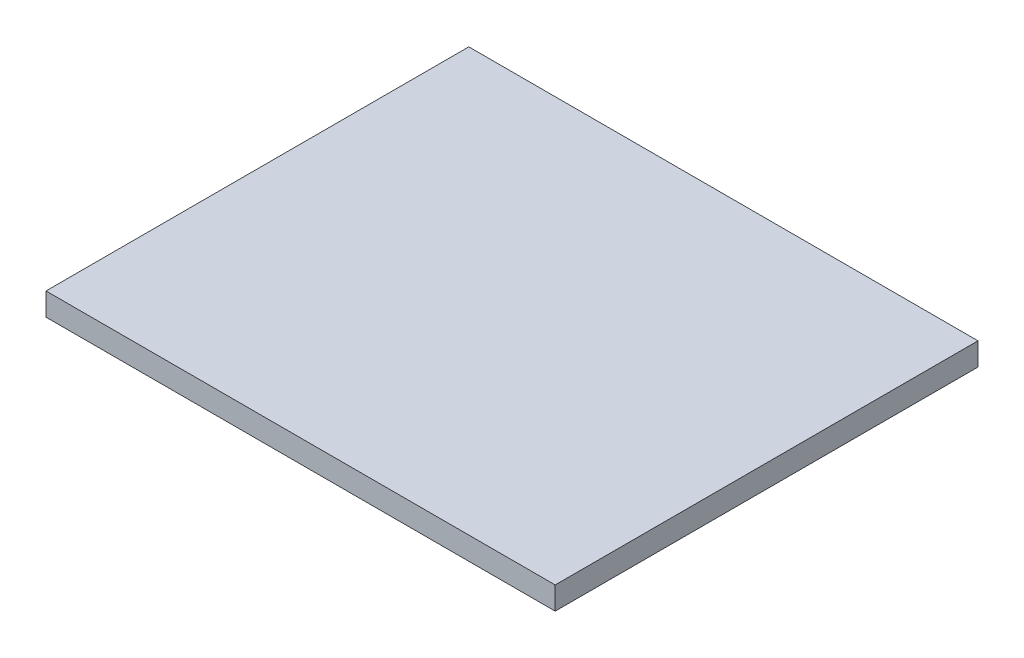
from build123d import *

# Parameters (mm, degrees)
SKETCH1_W           = 56
SKETCH1_H           = 46.5
BOSS_EXTRUDE1_DEPTH = 2.5
SKETCH2_W           = 51
SKETCH2_H           = 41.5
SKETCH2_W_2         = 46
SKETCH2_H_2         = 36.5
BOSS_EXTRUDE2_DEPTH = 2.5
CUT_EXTRUDE1_DEPTH  = 2.5
FILLET1_R           = 2


with BuildPart() as part:
    # Sketch1 → Boss-Extrude1 (new body)
    with BuildSketch(Plane(origin=(0, 0, 0), x_dir=(1, 0, 0), z_dir=(0, 1, 0))):
        Rectangle(SKETCH1_W, SKETCH1_H)
    extrude(amount=BOSS_EXTRUDE1_DEPTH)

    # Sketch2 → Boss-Extrude2 (add)
    with BuildSketch(Plane.XZ):
        Rectangle(SKETCH2_W, SKETCH2_H)
        Rectangle(SKETCH2_W_2, SKETCH2_H_2, mode=Mode.SUBTRACT)
    extrude(amount=BOSS_EXTRUDE2_DEPTH)

    # Sketch3 → Cut-Extrude1 (cut)
    with BuildSketch(Plane.XZ.offset(2.5)):
        Polygon((-3, 20.75), (3, 20.75), (3, 3), (25.5, 3), (25.5, -3), (3, -3), (3, -20.75), (-3, -20.75), (-3, -3), (-25.5, -3), (-25.5, 3), (-3, 3), align=None)
    extrude(amount=-CUT_EXTRUDE1_DEPTH, mode=Mode.SUBTRACT)

    # Fillet1
    fillet1_edges = [part.edges().sort_by_distance(p)[0] for p in [
        (-3, 0, 19.5),
        (3, 0, 19.5),
        (24.25, 0, 3),
        (24.25, 0, -3),
        (3, 0, -19.5),
        (-3, 0, -19.5),
        (-24.25, 0, -3),
        (-24.25, 0, 3),
    ]]
    fillet(fillet1_edges, radius=FILLET1_R)


solid = part.part
